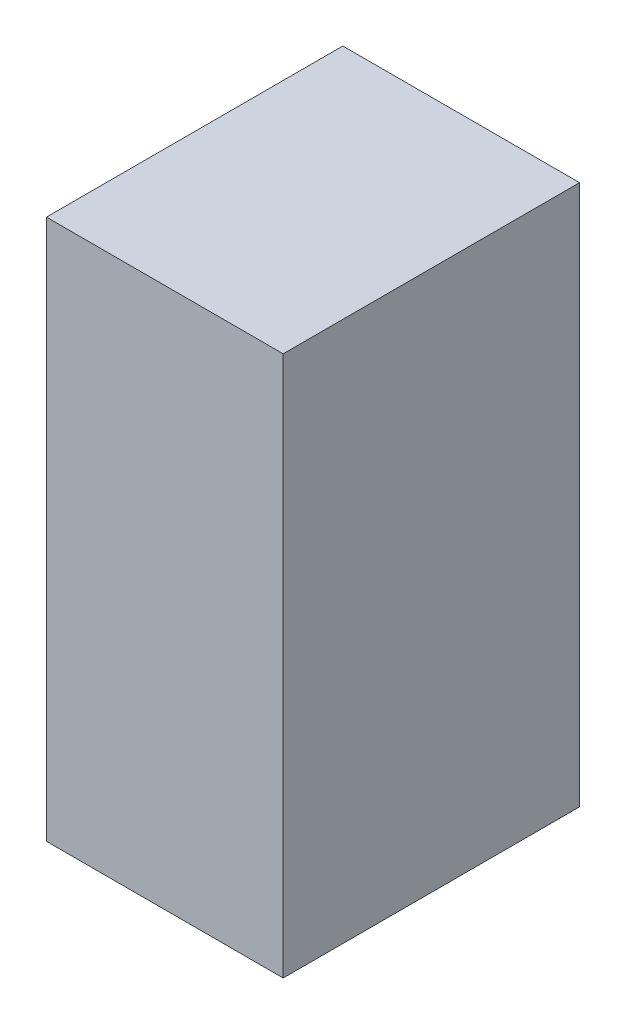
from build123d import *

# Parameters (mm, degrees)
SKETCH1_W           = 25.4
SKETCH1_H           = 31.8
BOSS_EXTRUDE1_DEPTH = 58


with BuildPart() as part:
    # Sketch1 → Boss-Extrude1 (new body)
    with BuildSketch(Plane(origin=(0, 0, 0), x_dir=(1, 0, 0), z_dir=(0, 1, 0))):
        Rectangle(SKETCH1_W, SKETCH1_H)
    extrude(amount=BOSS_EXTRUDE1_DEPTH)


solid = part.part
